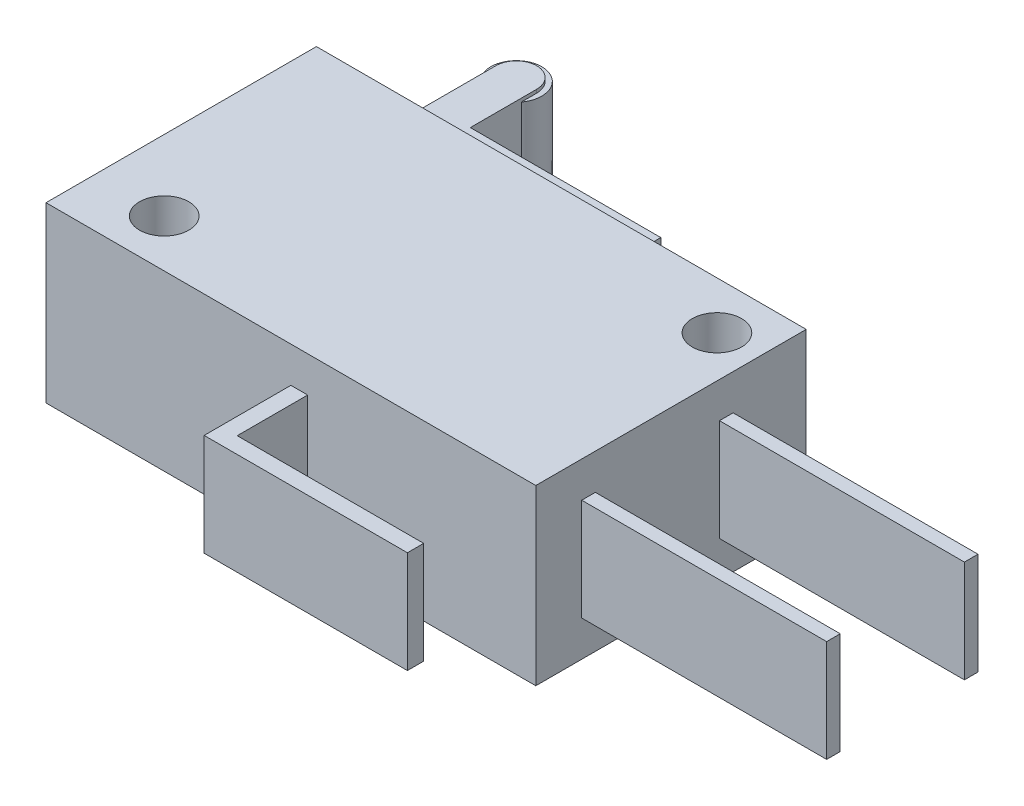
from build123d import *

# Parameters (mm, degrees)
SKETCH1_W                = 28.8
SKETCH1_H                = 15.9
BOSS_EXTRUDE2_DEPTH      = 10.2
SKETCH3_R                = 1.45
CUT_EXTRUDE1_DEPTH       = 17.45
SKETCH7_R                = 1.5
BOSS_EXTRUDE6_DEPTH      = 3.2
BOSS_EXTRUDE6_DEPTH_BACK = 3.2
BOSS_EXTRUDE7_DEPTH      = 3.4
BOSS_EXTRUDE7_DEPTH_BACK = 3.4
SKETCH9_W                = 14.4
SKETCH9_H                = 0.8
BOSS_EXTRUDE8_DEPTH      = 3
BOSS_EXTRUDE8_DEPTH_BACK = 3


with BuildPart() as part:
    # Sketch1 → Boss-Extrude2 (new body)
    with BuildSketch(Plane(origin=(0, 0, 0), x_dir=(1, 0, 0), z_dir=(0, 1, 0))):
        Rectangle(SKETCH1_W, SKETCH1_H)
    extrude(amount=BOSS_EXTRUDE2_DEPTH)

    # Sketch3 → Cut-Extrude1 (cut)
    with BuildSketch(Plane(origin=(0, 10.2, 0), x_dir=(1, 0, 0), z_dir=(0, 1, 0))):
        with Locations((11.95, 5.15)):
            Circle(SKETCH3_R)
        with Locations((-10.25, -5.15)):
            Circle(SKETCH3_R)
    extrude(amount=-CUT_EXTRUDE1_DEPTH, mode=Mode.SUBTRACT)



with BuildPart() as body_2:
    # Sketch7 → Boss-Extrude6 (new body, two sides)
    with BuildSketch(Plane(origin=(0, 5.1, 0), x_dir=(1, 0, 0), z_dir=(0, 1, 0))) as boss_extrude6_sk:
        with Locations((-8.65, 13.95)):
            Circle(SKETCH7_R)
    extrude(amount=BOSS_EXTRUDE6_DEPTH)
    extrude(boss_extrude6_sk.sketch, amount=-BOSS_EXTRUDE6_DEPTH_BACK)


with BuildPart() as part_1:
    add(part.part)

    add(body_2.part)  # Boss-Extrude7 merges body 2
    # Sketch8 → Boss-Extrude7 (add, two sides)
    with BuildSketch(Plane(origin=(0, 5.1, 0), x_dir=(1, 0, 0), z_dir=(0, 1, 0))) as boss_extrude7_sk:
        with BuildLine():
            ThreePointArc((-7.45, 13.95), (-8.65, 15.15), (-9.85, 13.95))
            Line((-9.85, 13.95), (-9.85, 10.05))
            Line((-9.85, 10.05), (-9.85, 9.648933868))
            Line((-9.85, 9.648933868), (-8.65, 9.648933868))
            Line((-8.65, 9.648933868), (-7.45, 9.648933868))
            Line((-7.45, 9.648933868), (3.238900305, 9.648933868))
            Line((3.238900305, 9.648933868), (3.238900305, 7.95))
            Line((3.238900305, 7.95), (3.75, 7.95))
            Line((3.75, 7.95), (3.75, 9.648933868))
            Line((3.75, 9.648933868), (3.75, 10.05))
            Line((3.75, 10.05), (3.238900305, 10.05))
            Line((3.238900305, 10.05), (-7.45, 10.05))
            Line((-7.45, 10.05), (-7.45, 13.95))
        make_face()
    extrude(amount=BOSS_EXTRUDE7_DEPTH)
    extrude(boss_extrude7_sk.sketch, amount=-BOSS_EXTRUDE7_DEPTH_BACK)

    # Sketch9 → Boss-Extrude8 (add, two sides)
    with BuildSketch(Plane(origin=(0, 5.1, 0), x_dir=(1, 0, 0), z_dir=(0, 1, 0))) as boss_extrude8_sk:
        with Locations((21.6, 3.25)):
            Rectangle(SKETCH9_W, SKETCH9_H)
        with Locations((21.6, -4.85)):
            Rectangle(SKETCH9_W, SKETCH9_H)
        Polygon((0, -7.95), (0, -13.05), (11.95, -13.05), (11.95, -12.093699041), (0.986707236, -12.093699041), (0.986707236, -7.95), align=None)
    extrude(amount=BOSS_EXTRUDE8_DEPTH)
    extrude(boss_extrude8_sk.sketch, amount=-BOSS_EXTRUDE8_DEPTH_BACK)


solid = part_1.part
